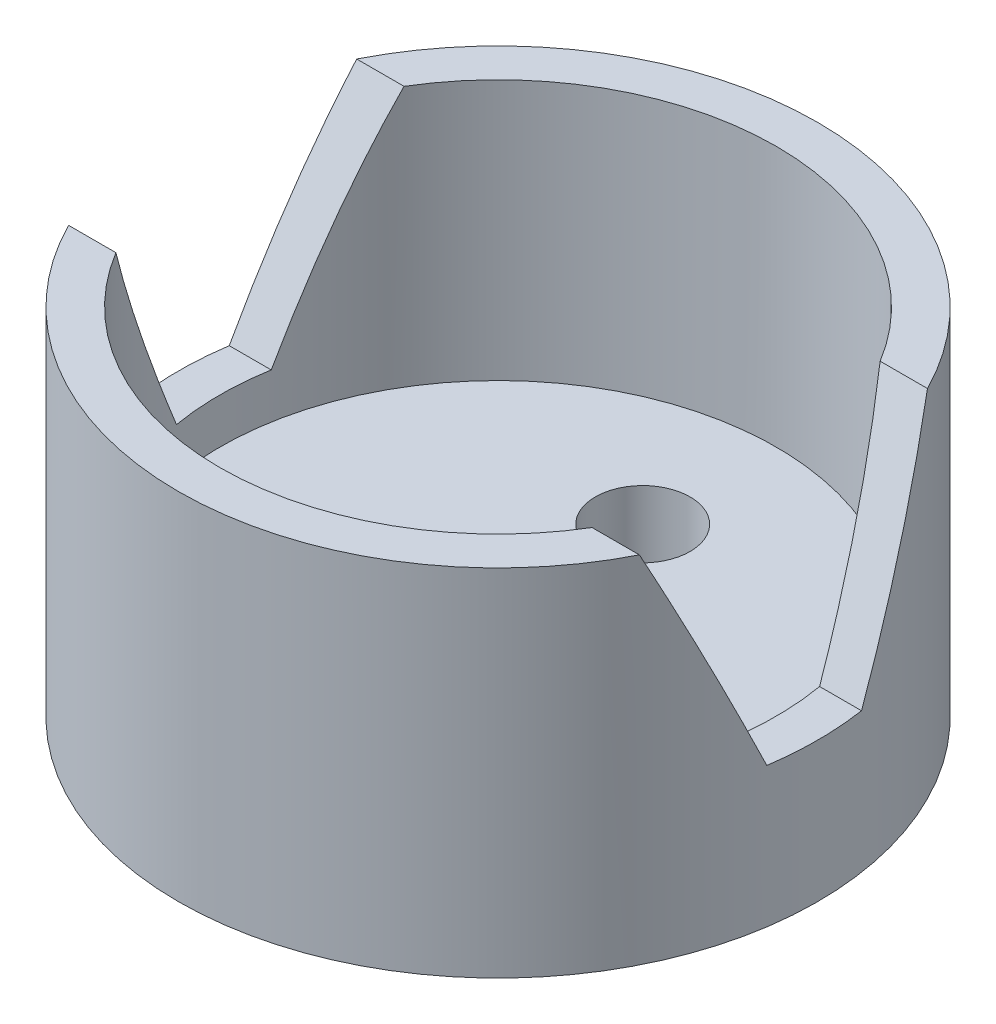
from build123d import *

# Parameters (mm, degrees)
SKETCH_1_R               = 13.5
EXTRUDE_1_DEPTH          = 15
SKETCH_2_R               = 11.75
CUT_EXTRUDE_1_DEPTH      = 11
SKETCH_3_R               = 2
CUT_EXTRUDE_2_DEPTH      = 5
CUT_EXTRUDE_3_DEPTH      = 14.5
CUT_EXTRUDE_3_DEPTH_BACK = 14.5


with BuildPart() as part:
    # Эскиз1 → Бобышка-Вытянуть1 (new body)
    with BuildSketch(Plane(origin=(0, 0, 0), x_dir=(1, 0, 0), z_dir=(0, 1, 0))):
        Circle(SKETCH_1_R)
    extrude(amount=EXTRUDE_1_DEPTH)

    # Эскиз2 → Вырез-Вытянуть1 (cut)
    with BuildSketch(Plane(origin=(0, 15, 0), x_dir=(1, 0, 0), z_dir=(0, 1, 0))):
        Circle(SKETCH_2_R)
    extrude(amount=-CUT_EXTRUDE_1_DEPTH, mode=Mode.SUBTRACT)

    # Эскиз3 → Вырез-Вытянуть2 (cut, through all)
    with BuildSketch(Plane(origin=(0, 4, 0), x_dir=(1, 0, 0), z_dir=(0, 1, 0))):
        with Locations((0, 6.108441075)):
            Circle(SKETCH_3_R)
    extrude(amount=-CUT_EXTRUDE_2_DEPTH, mode=Mode.SUBTRACT)

    # Эскиз4 → Вырез-Вытянуть3 (cut, two sides)
    with BuildSketch(Plane(origin=(0, 0, 0), x_dir=(0, 0, -1), z_dir=(1, 0, 0))) as cut_extrude_3_sk:
        Polygon((2, 5.907484345), (-2, 5.907484345), (-6.083122861, 15), (6.083122861, 15), align=None)
    extrude(amount=CUT_EXTRUDE_3_DEPTH, mode=Mode.SUBTRACT)
    extrude(cut_extrude_3_sk.sketch, amount=-CUT_EXTRUDE_3_DEPTH_BACK, mode=Mode.SUBTRACT)


solid = part.part
